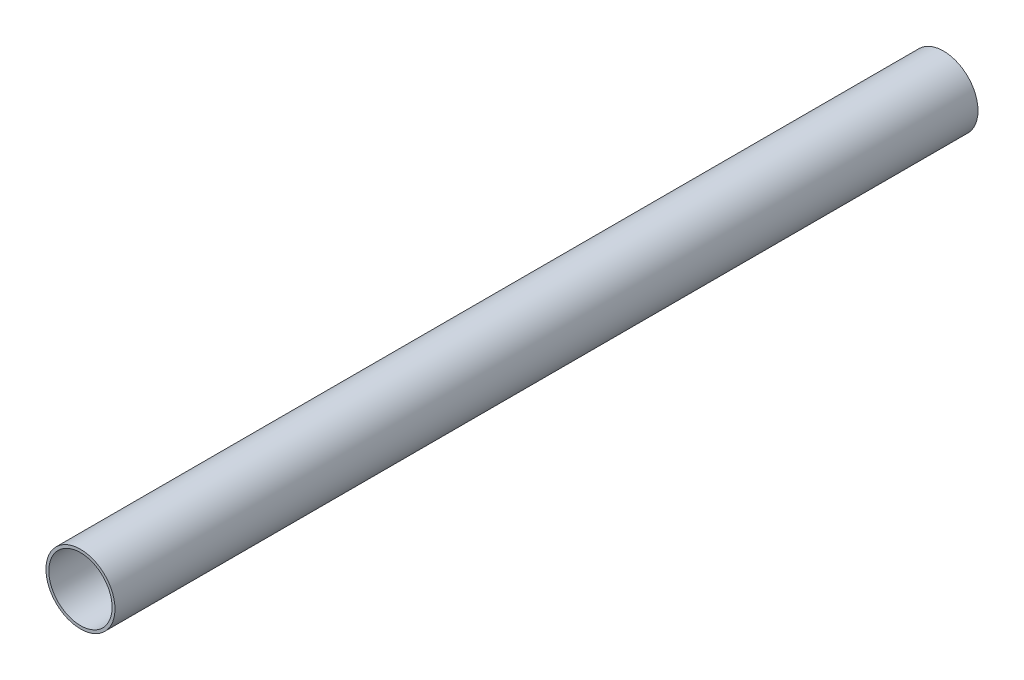
from build123d import *

# Parameters (mm, degrees)
ESQUISSE1_R        = 12
ESQUISSE1_R_2      = 11
BOSS_EXTRU_1_DEPTH = 300


with BuildPart() as part:
    # Esquisse1 → Boss.-Extru.1 (new body)
    with BuildSketch(Plane.XY):
        Circle(ESQUISSE1_R)
        Circle(ESQUISSE1_R_2, mode=Mode.SUBTRACT)
    extrude(amount=BOSS_EXTRU_1_DEPTH)


solid = part.part
